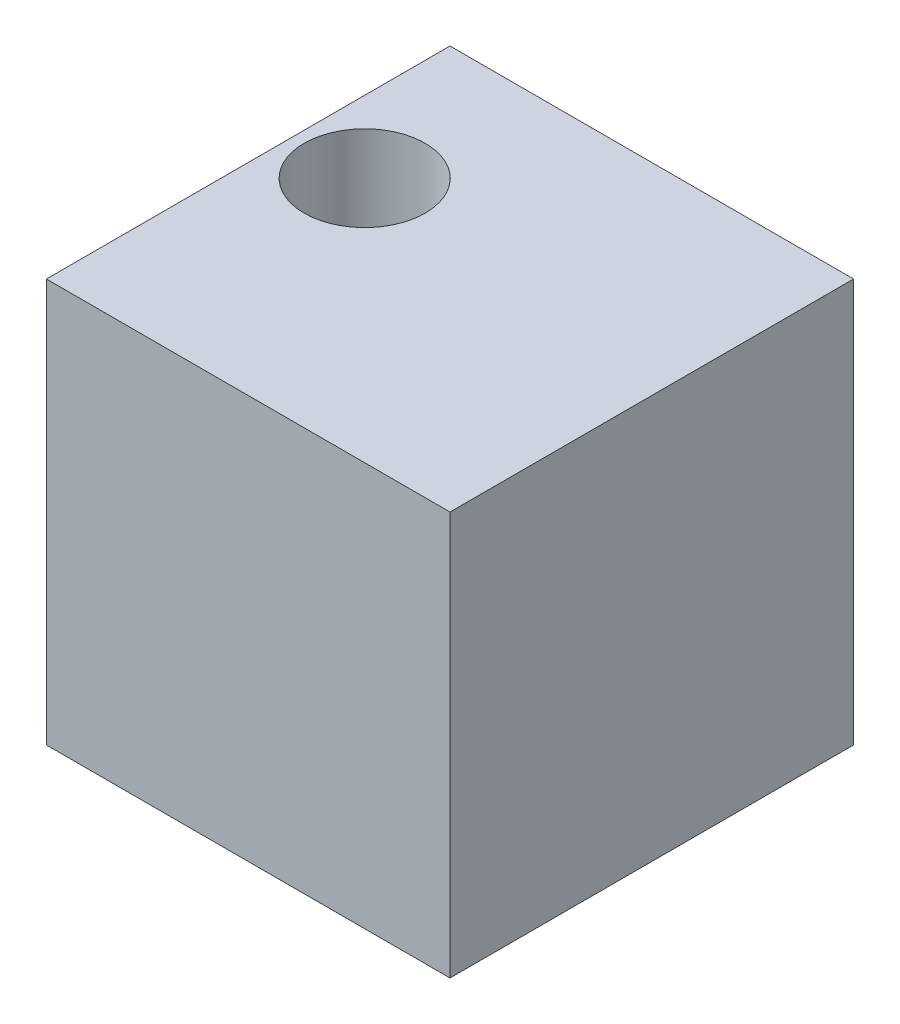
from build123d import *

# Parameters (mm, degrees)
SKETCH1_W           = 25.4
SKETCH1_H           = 25.4
BOSS_EXTRUDE1_DEPTH = 25.4
SKETCH3_R           = 3.81
CUT_EXTRUDE1_DEPTH  = 26.4


with BuildPart() as part:
    # Sketch1 → Boss-Extrude1 (new body)
    with BuildSketch(Plane.XY):
        with Locations((12.7, 12.7)):
            Rectangle(SKETCH1_W, SKETCH1_H)
    extrude(amount=BOSS_EXTRUDE1_DEPTH)

    # Sketch3 → Cut-Extrude1 (cut, through all)
    with BuildSketch(Plane(origin=(0, 25.4, 0), x_dir=(1, 0, 0), z_dir=(0, 1, 0))):
        with Locations((4.520477268, -9.891117385)):
            Circle(SKETCH3_R)
    extrude(amount=-CUT_EXTRUDE1_DEPTH, mode=Mode.SUBTRACT)


solid = part.part
